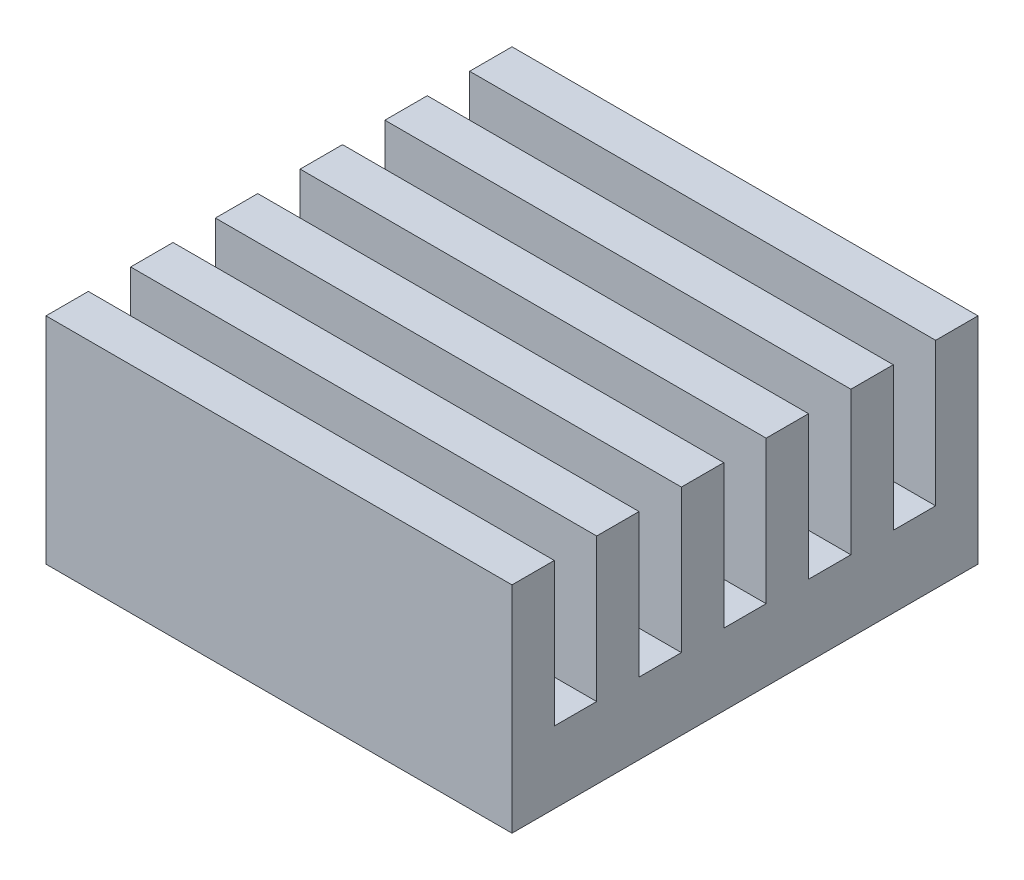
from build123d import *

# Parameters (mm, degrees)
SKETCH1_W      = 65
SKETCH1_H      = 65
EXTRUDE1_DEPTH = 30
SKETCH2_W      = 65
SKETCH2_H      = 5.91
EXTRUDE2_DEPTH = 20
SKETCH3_W      = 50
SKETCH3_H      = 50
EXTRUDE3_DEPTH = 1


with BuildPart() as part:
    # Sketch1 → Extrude1 (new body)
    with BuildSketch(Plane(origin=(0, 0, 0), x_dir=(1, 0, 0), z_dir=(0, 1, 0))):
        Rectangle(SKETCH1_W, SKETCH1_H)
    extrude(amount=EXTRUDE1_DEPTH)

    # Sketch2 → Extrude2 (cut)
    with BuildSketch(Plane(origin=(0, 30, 0), x_dir=(1, 0, 0), z_dir=(0, 1, 0))):
        with Locations((0, 23.635)):
            Rectangle(SKETCH2_W, SKETCH2_H)
        with Locations((0, 11.815)):
            Rectangle(SKETCH2_W, SKETCH2_H)
        with Locations((0, -0.005)):
            Rectangle(SKETCH2_W, SKETCH2_H)
        with Locations((0, -11.825)):
            Rectangle(SKETCH2_W, SKETCH2_H)
        with Locations((0, -23.645)):
            Rectangle(SKETCH2_W, SKETCH2_H)
    extrude(amount=-EXTRUDE2_DEPTH, mode=Mode.SUBTRACT)

    # Sketch3 → Extrude3 (add)
    with BuildSketch(Plane.XZ):
        Rectangle(SKETCH3_W, SKETCH3_H)
    extrude(amount=EXTRUDE3_DEPTH)


solid = part.part
